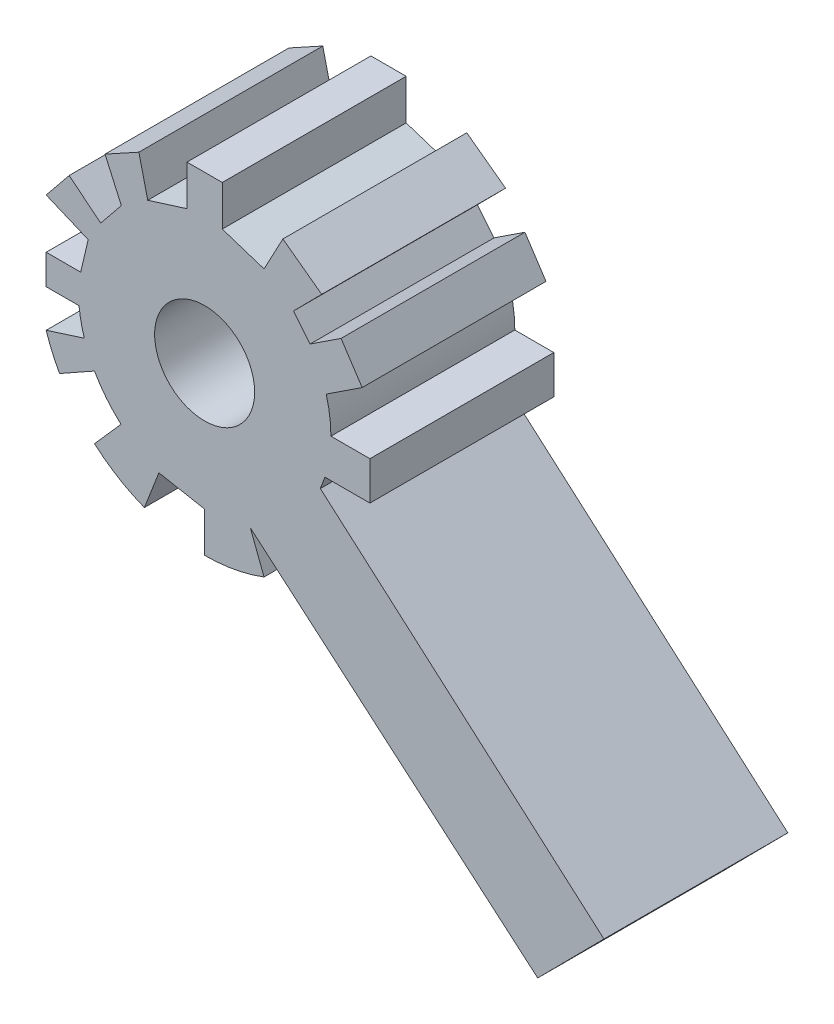
from build123d import *

# Parameters (mm, degrees)
SKETCH7_R           = 2.718976156
BOSS_EXTRUDE5_DEPTH = 5


with BuildPart() as part:
    # Sketch7 → Boss-Extrude5 (new body, symmetric)
    with BuildSketch(Plane.XY):
        with BuildLine():
            Line((-108.314342925, 18.989771489), (-110.232079527, 18.989771489))
            Line((-110.232079527, 18.989771489), (-110.232079527, 16.794247959))
            Line((-110.232079527, 16.794247959), (-112.368671741, 16.124256422))
            Line((-112.368671741, 16.124256422), (-112.848780488, 18.148130182))
            Line((-112.848780488, 18.148130182), (-114.689202025, 17.136193302))
            Line((-114.689202025, 17.136193302), (-113.802244367, 15.156219029))
            Line((-113.802244367, 15.156219029), (-114.926218754, 13.769061439))
            Line((-114.926218754, 13.769061439), (-116.638184972, 15.156219029))
            Line((-116.638184972, 15.156219029), (-117.890010894, 13.611272945))
            Line((-117.890010894, 13.611272945), (-115.604979487, 12.652206929))
            Line((-115.604979487, 12.652206929), (-116.014015282, 10.916483695))
            Line((-116.014015282, 10.916483695), (-117.890010894, 10.916483695))
            Line((-117.890010894, 10.916483695), (-117.890010894, 9.290502395))
            Line((-117.890010894, 9.290502395), (-116.103879087, 9.290502395))
            ThreePointArc((-116.103879087, 9.290502395), (-115.994870907, 8.589969318), (-115.814214218, 7.904409303))
            Line((-115.814214218, 7.904409303), (-117.890010894, 7.24106602))
            ThreePointArc((-117.890010894, 7.24106602), (-117.56834444, 6.386019614), (-117.162078542, 5.567776566))
            Line((-117.162078542, 5.567776566), (-115.261641584, 6.634217149))
            ThreePointArc((-115.261641584, 6.634217149), (-114.615525484, 5.680316792), (-113.819022014, 4.847866116))
            Line((-113.819022014, 4.847866116), (-115.261641584, 3.214524472))
            ThreePointArc((-115.261641584, 3.214524472), (-113.978252901, 2.268462787), (-112.548700742, 1.562417569))
            Line((-112.548700742, 1.562417569), (-111.759631654, 3.593753614))
            Line((-111.759631654, 3.593753614), (-109.273211226, 3.127790889))
            Line((-109.273211226, 3.127790889), (-109.273211226, 0.948580907))
            ThreePointArc((-109.273211226, 0.948580907), (-107.630782877, 1.098932073), (-106.042950797, 1.544987721))
            Line((-106.042950797, 1.544987721), (-106.785965128, 3.488554168))
            Line((-106.785965128, 3.488554168), (-91.16192211, -9.89798132))
            Line((-91.16192211, -9.89798132), (-87.560983072, -6.260758332))
            Line((-87.560983072, -6.260758332), (-102.982615742, 7.24106602))
            Line((-102.982615742, 7.24106602), (-102.732208234, 7.904409303))
            Line((-102.732208234, 7.904409303), (-100.286956522, 7.904409303))
            Line((-100.286956522, 7.904409303), (-100.286956522, 9.994657565))
            Line((-100.286956522, 9.994657565), (-102.40634455, 9.994657565))
            ThreePointArc((-102.40634455, 9.994657565), (-102.470378556, 10.930245938), (-102.661286329, 11.848385459))
            Line((-102.661286329, 11.848385459), (-100.710110893, 13.132180531))
            Line((-100.710110893, 13.132180531), (-101.856516581, 14.874544766))
            Line((-101.856516581, 14.874544766), (-103.536684982, 13.769061439))
            Line((-103.536684982, 13.769061439), (-104.442004457, 14.874544766))
            Line((-104.442004457, 14.874544766), (-102.908814063, 16.423183965))
            Line((-102.908814063, 16.423183965), (-105.01782302, 17.977337199))
            Line((-105.01782302, 17.977337199), (-106.042950797, 16.054300748))
            Line((-106.042950797, 16.054300748), (-108.314342925, 16.794247959))
            Line((-108.314342925, 16.794247959), (-108.314342925, 18.989771489))
        make_face()
        with Locations((-109.273211226, 9.994657565)):
            Circle(SKETCH7_R, mode=Mode.SUBTRACT)
    extrude(amount=BOSS_EXTRUDE5_DEPTH, both=True)


solid = part.part
